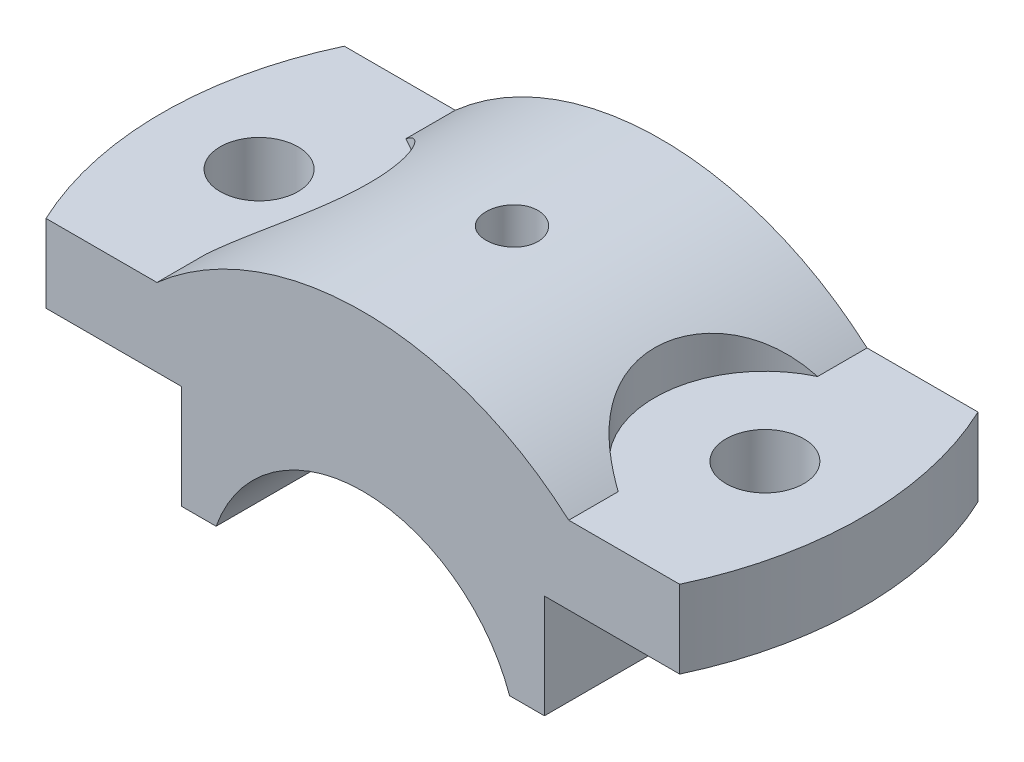
from build123d import *

# Parameters (mm, degrees)
BOSS_EXTRUDE1_DEPTH     = 23
BOSS_EXTRUDE4_START     = 24
BOSS_EXTRUDE4_DEPTH     = 12
SKETCH4_R               = 3
CUT_EXTRUDE1_DEPTH      = 13
CUT_EXTRUDE1_DEPTH_BACK = 29
SKETCH5_R               = 4
CUT_EXTRUDE2_DEPTH      = 16
F_12_0MM_DOWEL_HOLE1_D  = 12
CUT_EXTRUDE3_DEPTH      = 16


with BuildPart() as part:
    # Sketch1 → Boss-Extrude1 (new body, symmetric)
    with BuildSketch(Plane.XY):
        with BuildLine():
            Line((31.749015733, 36), (31.749015733, 24))
            Line((31.749015733, 24), (28, 24))
            Line((28, 24), (28, 8))
            Line((28, 8), (22.627416998, 8))
            ThreePointArc((22.627416998, 8), (0, 24), (-22.627416998, 8))
            Line((-22.627416998, 8), (-28, 8))
            Line((-28, 8), (-28, 24))
            Line((-28, 24), (-31.749015733, 24))
            Line((-31.749015733, 24), (-31.749015733, 36))
            ThreePointArc((-31.749015733, 36), (0, 48), (31.749015733, 36))
        make_face()
    extrude(amount=BOSS_EXTRUDE1_DEPTH, both=True)

    # Sketch3 → Boss-Extrude4 (add)
    with BuildSketch(Plane(origin=(0, 0, 0), x_dir=(1, 0, 0), z_dir=(0, 1, 0)).offset(BOSS_EXTRUDE4_START)):
        with BuildLine():
            Line((31.749015733, -23), (31.749015733, 23))
            Line((31.749015733, 23), (48.856934001, 23))
            ThreePointArc((48.856934001, 23), (54, 0), (48.856934001, -23))
            Line((48.856934001, -23), (31.749015733, -23))
        make_face()
    boss_extrude4 = extrude(amount=BOSS_EXTRUDE4_DEPTH)

    # Mirror2: Boss-Extrude4 across plane
    add(boss_extrude4.mirror(Plane(origin=(0, 0, 0), x_dir=(0, 0, 1), z_dir=(1, 0, 0))))

    # Sketch4 → Cut-Extrude1 (cut, two sides)
    with BuildSketch(Plane(origin=(0, 36, 0), x_dir=(1, 0, 0), z_dir=(0, 1, 0))) as cut_extrude1_sk:
        Circle(SKETCH4_R)
    extrude(amount=CUT_EXTRUDE1_DEPTH, mode=Mode.SUBTRACT)
    extrude(cut_extrude1_sk.sketch, amount=-CUT_EXTRUDE1_DEPTH_BACK, mode=Mode.SUBTRACT)

    # Sketch5 → Cut-Extrude2 (cut)
    with BuildSketch(Plane(origin=(0, 48, 0), x_dir=(1, 0, 0), z_dir=(0, 1, 0))):
        Circle(SKETCH5_R)
    extrude(amount=-CUT_EXTRUDE2_DEPTH, mode=Mode.SUBTRACT)

    # Ø12.0mm Dowel Hole1 (through all)
    with Locations(Plane(origin=(0, 36, 0), x_dir=(1, 0, 0), z_dir=(0, 1, 0))):
        with Locations((-39, 0), (39, 0)):
            Hole(F_12_0MM_DOWEL_HOLE1_D / 2)

    # Sketch8 → Cut-Extrude3 (cut)
    with BuildSketch(Plane(origin=(0, 36, 0), x_dir=(1, 0, 0), z_dir=(0, 1, 0))):
        with BuildLine():
            Line((31.749015733, -15.376060196), (31.749015733, 15.376060196))
            ThreePointArc((31.749015733, 15.376060196), (22, 0), (31.749015733, -15.376060196))
        make_face()
    cut_extrude3 = extrude(amount=CUT_EXTRUDE3_DEPTH, mode=Mode.SUBTRACT)

    # Mirror3: Cut-Extrude3 across plane
    add(cut_extrude3.mirror(Plane(origin=(0, 0, 0), x_dir=(0, 0, 1), z_dir=(1, 0, 0))), mode=Mode.SUBTRACT)


solid = part.part
